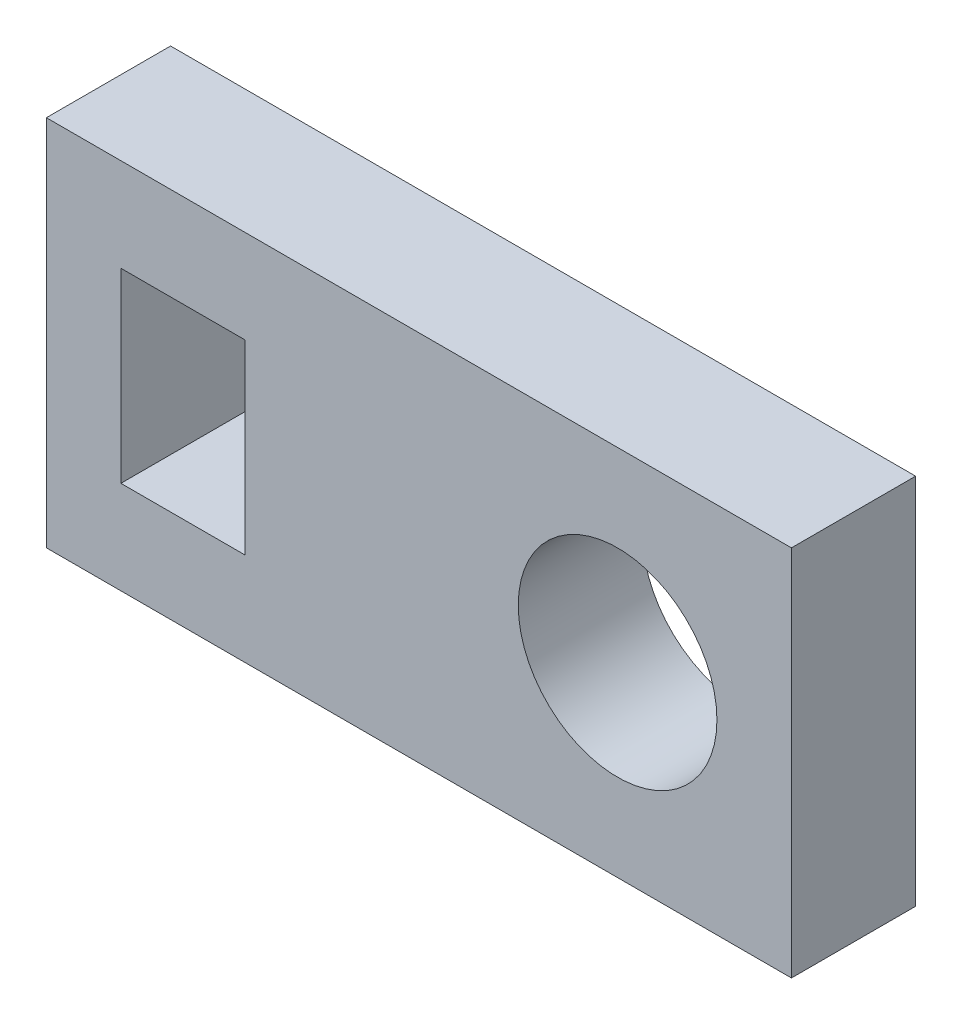
from build123d import *

# Parameters (mm, degrees)
SKETCH1_W           = 30
SKETCH1_H           = 15
SKETCH1_R           = 4
SKETCH1_W_2         = 5
SKETCH1_H_2         = 7.5
BOSS_EXTRUDE1_DEPTH = 5


with BuildPart() as part:
    # Sketch1 → Boss-Extrude1 (new body)
    with BuildSketch(Plane.XY):
        with Locations((15, 7.5)):
            Rectangle(SKETCH1_W, SKETCH1_H)
        with Locations((23, 7.5)):
            Circle(SKETCH1_R, mode=Mode.SUBTRACT)
        with Locations((5.5, 7.5)):
            Rectangle(SKETCH1_W_2, SKETCH1_H_2, mode=Mode.SUBTRACT)
    extrude(amount=BOSS_EXTRUDE1_DEPTH)


solid = part.part
